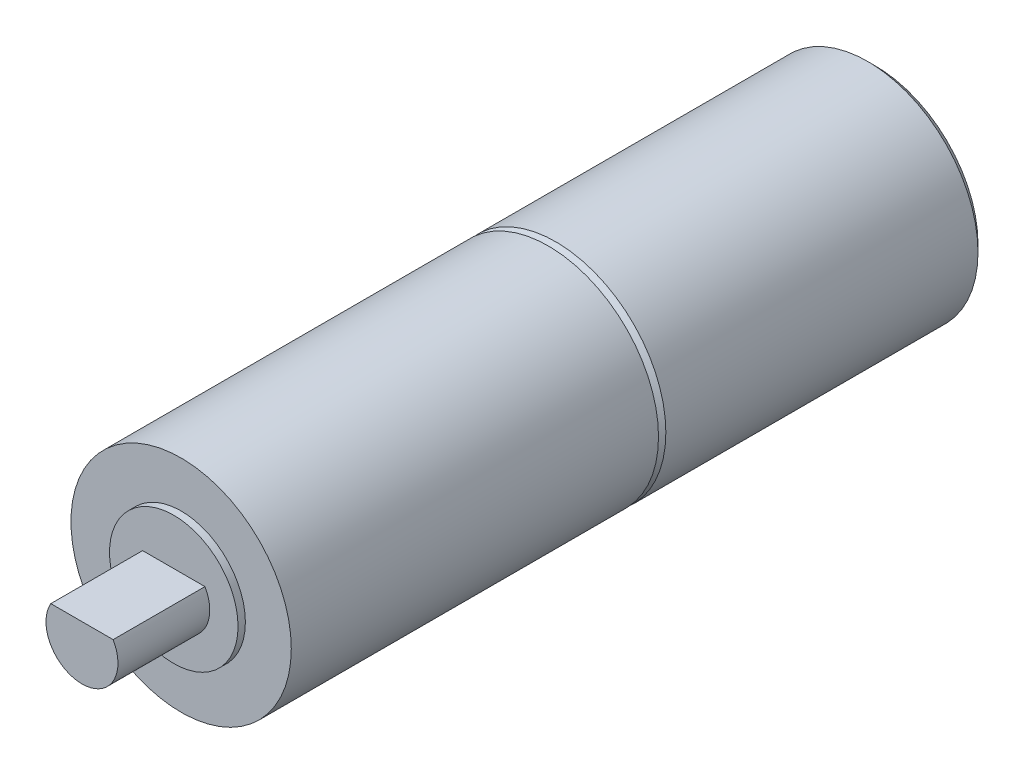
from build123d import *

# Parameters (mm, degrees)
SKETCH1_R           = 3
BOSS_EXTRUDE1_DEPTH = 8.9
CHAMFER1_SIZE       = 0.2
SKETCH2_R           = 3
BOSS_EXTRUDE2_DEPTH = 10
SKETCH3_R           = 1.75
BOSS_EXTRUDE3_DEPTH = 0.2
BOSS_EXTRUDE4_DEPTH = 2.5


with BuildPart() as part:
    # Sketch1 → Boss-Extrude1 (new body)
    with BuildSketch(Plane.XY):
        Circle(SKETCH1_R)
    extrude(amount=BOSS_EXTRUDE1_DEPTH)

    # Chamfer1
    chamfer1_edges = [part.edges().sort_by_distance(p)[0] for p in [
        (-3, 0, 0),
        (-3, 0, 8.9),
    ]]
    chamfer(chamfer1_edges, length=CHAMFER1_SIZE)

    # Sketch2 → Boss-Extrude2 (add)
    with BuildSketch(Plane.XY.offset(8.9)):
        Circle(SKETCH2_R)
    extrude(amount=BOSS_EXTRUDE2_DEPTH)

    # Sketch3 → Boss-Extrude3 (add)
    with BuildSketch(Plane.XY.offset(18.9)):
        Circle(SKETCH3_R)
    extrude(amount=BOSS_EXTRUDE3_DEPTH)

    # Sketch5 → Boss-Extrude4 (add)
    with BuildSketch(Plane.XY.offset(19.1)):
        with BuildLine():
            Line((0, 0.49), (0.848704896, 0.49))
            ThreePointArc((0.848704896, 0.49), (0, -0.98), (-0.848704896, 0.49))
            Line((-0.848704896, 0.49), (0, 0.49))
        make_face()
    extrude(amount=BOSS_EXTRUDE4_DEPTH)


solid = part.part
